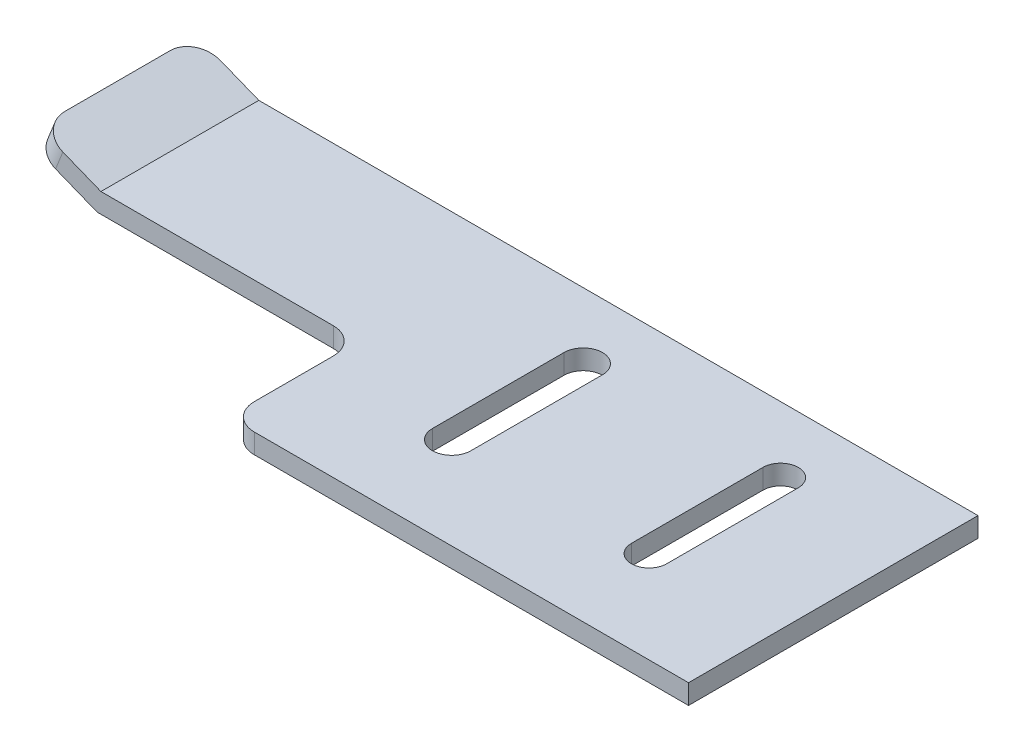
from build123d import *

# Parameters (mm, degrees)
BOSS_EXTRUDE1_DEPTH = 22
SKETCH2_W           = 32.324702558
SKETCH2_H           = 10
CUT_EXTRUDE1_DEPTH  = 22
FILLET2_R           = 2


with BuildPart() as part:
    # Sketch1 → Boss-Extrude1 (new body)
    with BuildSketch(Plane.XY):
        Polygon((-2.531920895, 4.378113215), (-7.546246883, 6.382242673), (-6.989544256, 7.775111003), (-2.24326139, 5.878113215), (52.413753117, 5.878113215), (52.413753117, 4.378113215), align=None)
    extrude(amount=BOSS_EXTRUDE1_DEPTH)

    # Sketch2 → Cut-Extrude1 (cut)
    with BuildSketch(Plane.XZ.offset(-4.378113215)):
        with Locations((1.251401838, 17)):
            Rectangle(SKETCH2_W, SKETCH2_H)
        with BuildLine():
            Line((28.876886466, 15), (28.876886466, 5))
            ThreePointArc((28.876886466, 5), (27.413753117, 3.536866651), (25.950619767, 5))
            Line((25.950619767, 5), (25.950619767, 15))
            ThreePointArc((25.950619767, 15), (27.413753117, 16.463133349), (28.876886466, 15))
        make_face()
        with BuildLine():
            Line((43.757050896, 15), (43.757050896, 5))
            ThreePointArc((43.757050896, 5), (42.413753117, 3.656702221), (41.070455337, 5))
            Line((41.070455337, 5), (41.070455337, 15))
            ThreePointArc((41.070455337, 15), (42.413753117, 16.343297779), (43.757050896, 15))
        make_face()
    extrude(amount=-CUT_EXTRUDE1_DEPTH, mode=Mode.SUBTRACT)

    # Fillet2
    fillet2_edges = [part.edges().sort_by_distance(p)[0] for p in [
        (17.413753117, 5.128113215, 22),
        (-7.26789557, 7.078676838, 12),
        (17.413753117, 5.128113215, 12),
        (-7.26789557, 7.078676838, 0),
    ]]
    fillet(fillet2_edges, radius=FILLET2_R)


solid = part.part
